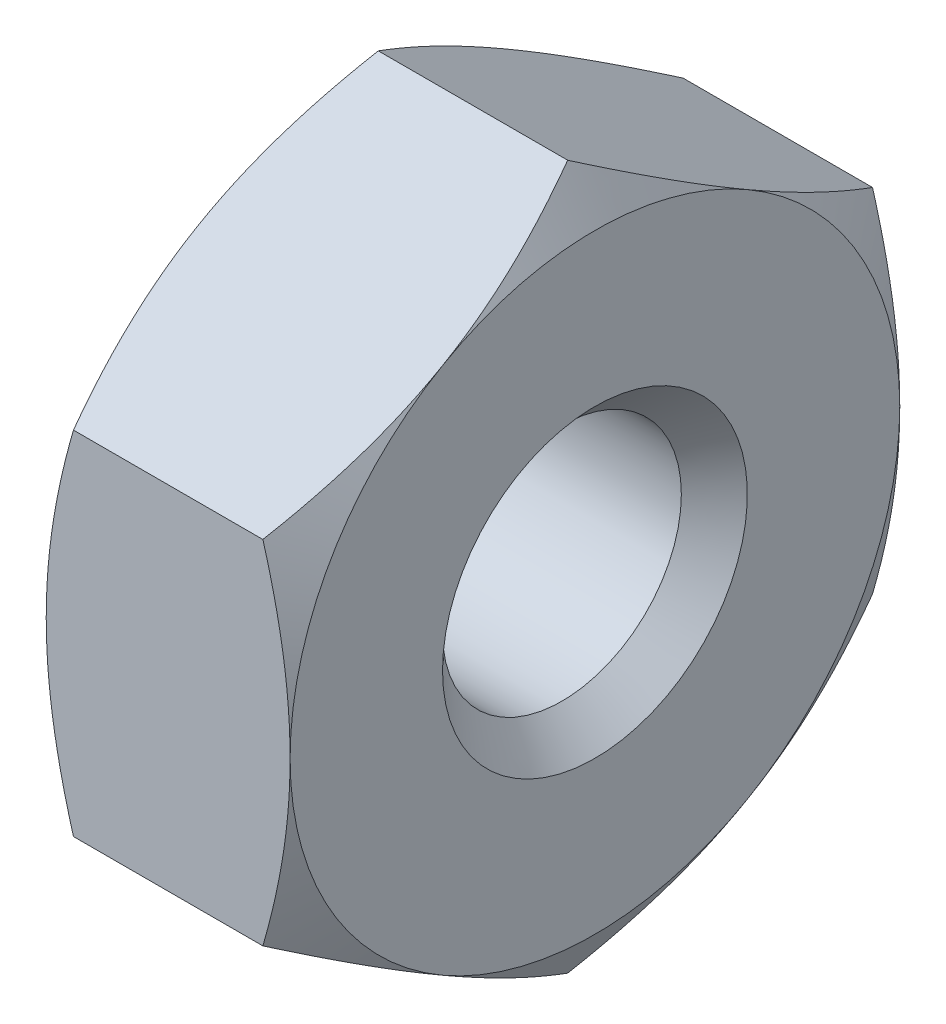
from build123d import *

# Parameters (mm, degrees)
SKETCH2_W          = 6
SKETCH2_H          = 6
CUT_EXTRUDE1_DEPTH = 1.6


with BuildPart() as part:
    # Sketch1 → Revolve1 (revolve)
    with BuildSketch(Plane.XY):
        Polygon((0, 0), (0, 2), (0.230940108, 2.4), (1.369059892, 2.4), (1.6, 2), (1.6, 0), align=None)
    revolve(axis=Axis((1.6, 0, 0), (-1, 0, 0)))

    # Sketch2 → Cut-Extrude1 (cut)
    with BuildSketch(Plane(origin=(0, 0, 0), x_dir=(0, 0, -1), z_dir=(1, 0, 0))):
        Rectangle(SKETCH2_W, SKETCH2_H)
        Polygon((-2, -1.154700538), (0, -2.309401077), (2, -1.154700538), (2, 1.154700538), (0, 2.309401077), (-2, 1.154700538), align=None, mode=Mode.SUBTRACT)
    extrude(amount=CUT_EXTRUDE1_DEPTH, mode=Mode.SUBTRACT)

    # Sketch3 → Cut-Revolve1 (revolve, cut)
    with BuildSketch(Plane.XY):
        Polygon((0, 0), (0, 1), (0.2165, 0.7835), (1.3835, 0.7835), (1.6, 1), (1.6, 0), align=None)
    revolve(axis=Axis((1.6, 0, 0), (-1, 0, 0)), mode=Mode.SUBTRACT)


solid = part.part
